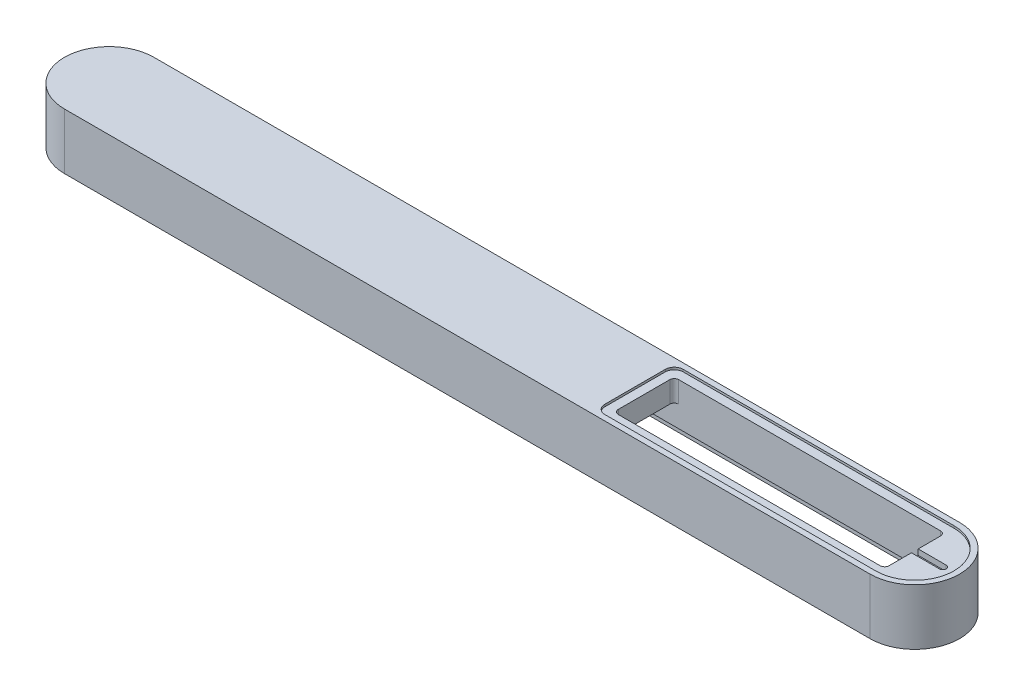
from build123d import *

# Parameters (mm, degrees)
BOSS_EXTRUDE1_DEPTH = 50
CUT_EXTRUDE2_DEPTH  = 4
CUT_EXTRUDE5_DEPTH  = 2
CUT_EXTRUDE7_DEPTH  = 20
CUT_EXTRUDE9_DEPTH  = 25
CUT_EXTRUDE14_DEPTH = 6
HOLE1_D             = 6
SKETCH18_W          = 25
SKETCH18_H          = 6
CUT_EXTRUDE15_DEPTH = 5


with BuildPart() as part:
    # Sketch1 → Boss-Extrude1 (new body)
    with BuildSketch(Plane(origin=(0, 0, 0), x_dir=(1, 0, 0), z_dir=(0, 1, 0))):
        with BuildLine():
            Line((-360, 39.99999406), (360, 39.99999406))
            ThreePointArc((360, 39.99999406), (399.999998105, -4.045e-06), (360, -40))
            Line((360, -40), (-360, -40))
            ThreePointArc((-360, -40), (-399.99999406, -5.94e-06), (-360, 39.99999406))
        make_face()
    extrude(amount=BOSS_EXTRUDE1_DEPTH)

    # Sketch4 → Cut-Extrude2 (cut)
    with BuildSketch(Plane.XZ):
        with BuildLine():
            Line((360, 35.000001075), (-360, 35.000001485))
            ThreePointArc((-360, 35.000001485), (-394.999995545, 5.94e-06), (-360, -34.999989605))
            Line((-360, -34.999989605), (360.000000021, -34.99999406))
            ThreePointArc((360.000000021, -34.99999406), (394.999998105, 4.055e-06), (360, 35.000001075))
        make_face()
    extrude(amount=-CUT_EXTRUDE2_DEPTH, mode=Mode.SUBTRACT)

    # Sketch6 → Cut-Extrude5 (cut)
    with BuildSketch(Plane(origin=(0, 50, 0), x_dir=(1, 0, 0), z_dir=(0, 1, 0))):
        with BuildLine():
            Line((360.000000021, 34.99999406), (117.999999967, 34.999993062))
            ThreePointArc((117.999999967, 34.999993062), (112.343145739, 32.6568473), (110, 26.999993062))
            Line((110, 26.999993062), (110, -27))
            ThreePointArc((110, -27), (112.343145751, -32.656854249), (118, -35))
            Line((118, -35), (360, -35))
            ThreePointArc((360, -35), (394.999995955, -4.055e-06), (360.000000021, 34.99999406))
        make_face()
    extrude(amount=-CUT_EXTRUDE5_DEPTH, mode=Mode.SUBTRACT)

    # Sketch7 → Cut-Extrude7 (cut)
    with BuildSketch(Plane(origin=(0, 48, 0), x_dir=(1, 0, 0), z_dir=(0, 1, 0))):
        with BuildLine():
            Line((122, 26.999992985), (356, 26.999992985))
            ThreePointArc((356, 26.999992985), (358.828427125, 25.82842011), (360, 22.999992985))
            Line((360, 22.999992985), (360, -23))
            ThreePointArc((360, -23), (358.828427125, -25.828427125), (356, -27))
            Line((356, -27), (122, -27))
            ThreePointArc((122, -27), (119.171572875, -25.828427125), (118, -23))
            Line((118, -23), (118, 22.999992985))
            ThreePointArc((118, 22.999992985), (119.171572875, 25.82842011), (122, 26.999992985))
        make_face()
    extrude(amount=-CUT_EXTRUDE7_DEPTH, mode=Mode.SUBTRACT)

    # Sketch2 → Cut-Extrude9 (cut)
    with BuildSketch(Plane.XZ.offset(-4)):
        with BuildLine():
            Line((356, 27), (-356, 27))
            ThreePointArc((-356, 27), (-358.828427125, 25.828427125), (-360, 23))
            Line((-360, 23), (-360, -22.99999406))
            ThreePointArc((-360, -22.99999406), (-358.828427125, -25.828421185), (-356, -26.99999406))
            Line((-356, -26.99999406), (356, -26.99999406))
            ThreePointArc((356, -26.99999406), (358.828427125, -25.828421185), (360, -22.99999406))
            Line((360, -22.99999406), (360, 23))
            ThreePointArc((360, 23), (358.828427125, 25.828427125), (356, 27))
        make_face()
    extrude(amount=-CUT_EXTRUDE9_DEPTH, mode=Mode.SUBTRACT)

    # Sketch15 → Cut-Extrude14 (cut)
    with BuildSketch(Plane.XZ.offset(-4)):
        with BuildLine():
            Line((-360, -30), (360, -30))
            ThreePointArc((360, -30), (364, -26), (360, -22))
            Line((360, -22), (360, -22.99999406))
            ThreePointArc((360, -22.99999406), (358.828427125, -25.828421185), (356, -26.99999406))
            Line((356, -26.99999406), (-356, -26.99999406))
            ThreePointArc((-356, -26.99999406), (-358.828427125, -25.828421185), (-360, -22.99999406))
            Line((-360, -22.99999406), (-360, -22))
            ThreePointArc((-360, -22), (-364, -26), (-360, -30))
        make_face()
        with BuildLine():
            Line((360, 23), (360, 22))
            ThreePointArc((360, 22), (364, 26), (360, 30))
            Line((360, 30), (-360, 30))
            ThreePointArc((-360, 30), (-364, 26), (-360, 22))
            Line((-360, 22), (-360, 23))
            ThreePointArc((-360, 23), (-358.828427125, 25.828427125), (-356, 27))
            Line((-356, 27), (356, 27))
            ThreePointArc((356, 27), (358.828427125, 25.828427125), (360, 23))
        make_face()
    extrude(amount=-CUT_EXTRUDE14_DEPTH, mode=Mode.SUBTRACT)

    # Hole1 (through all)
    with Locations(Plane(origin=(0, 4, 0), x_dir=(-1, 0, 0), z_dir=(0, -1, 0))):
        with Locations((-385, 0)):
            Hole(HOLE1_D / 2)

    # Sketch18 → Cut-Extrude15 (cut)
    with BuildSketch(Plane(origin=(0, 48, 0), x_dir=(1, 0, 0), z_dir=(0, 1, 0))):
        with Locations((372.5, 0)):
            Rectangle(SKETCH18_W, SKETCH18_H)
    extrude(amount=-CUT_EXTRUDE15_DEPTH, mode=Mode.SUBTRACT)


solid = part.part
